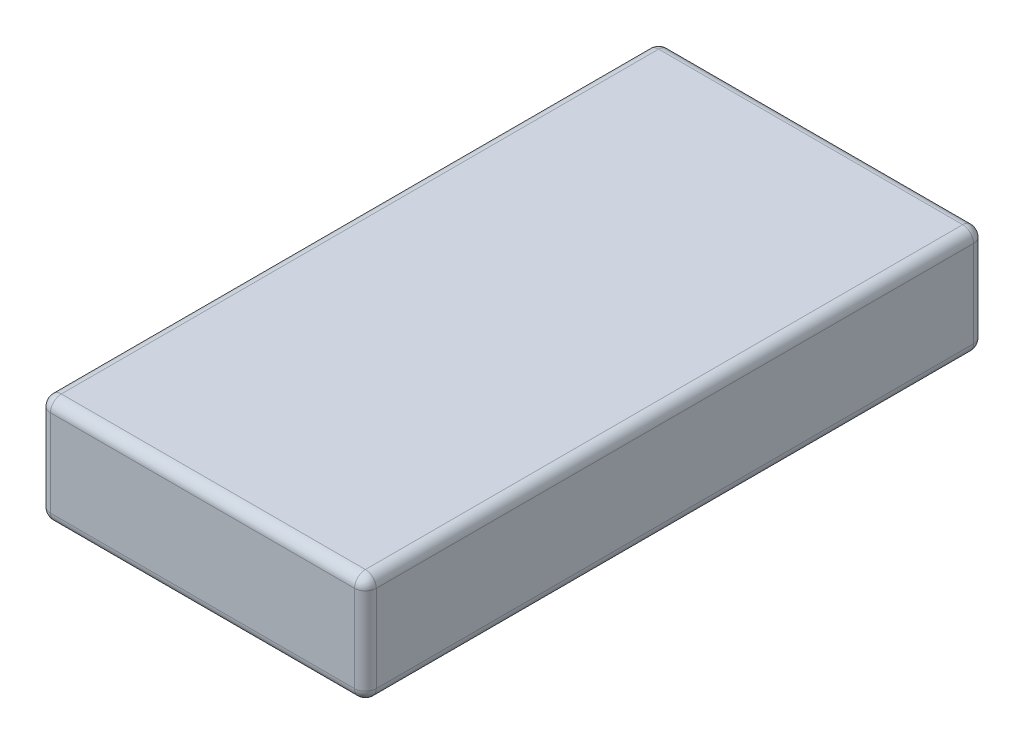
from build123d import *

# Parameters (mm, degrees)
SKETCH1_W           = 30
SKETCH1_H           = 10
BOSS_EXTRUDE1_DEPTH = 57
FILLET1_R           = 1


with BuildPart() as part:
    # Sketch1 → Boss-Extrude1 (new body)
    with BuildSketch(Plane.XY):
        Rectangle(SKETCH1_W, SKETCH1_H)
    extrude(amount=BOSS_EXTRUDE1_DEPTH)

    # Fillet1
    fillet1_edges = [part.edges().sort_by_distance(p)[0] for p in [
        (-15, 0, 57),
        (0, -5, 57),
        (15, 0, 57),
        (0, -5, 0),
        (-15, 0, 0),
        (0, 5, 0),
        (15, 0, 0),
        (0, 5, 57),
        (15, -5, 28.5),
        (-15, -5, 28.5),
        (-15, 5, 28.5),
        (15, 5, 28.5),
    ]]
    fillet(fillet1_edges, radius=FILLET1_R)


solid = part.part
